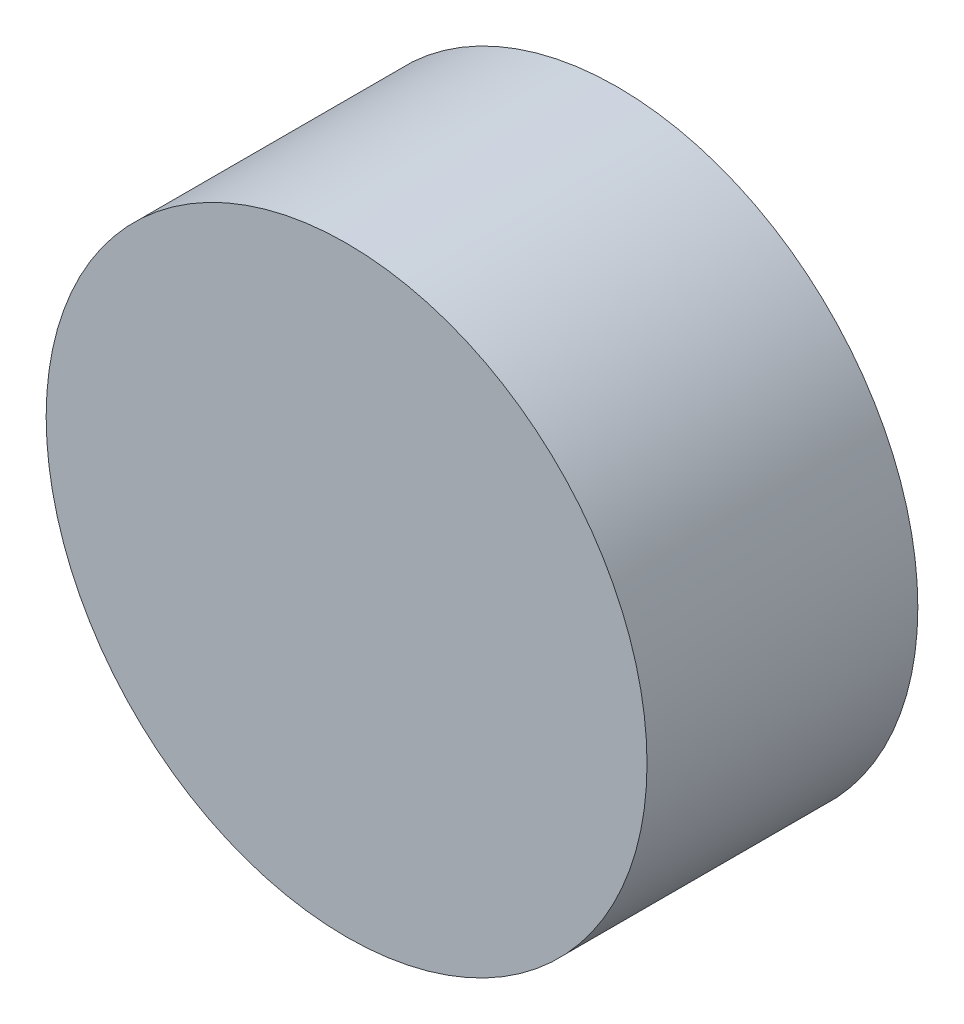
from build123d import *

# Parameters (mm, degrees)
ESQUISSE1_R        = 35.5
BOSS_EXTRU_1_DEPTH = 32


with BuildPart() as part:
    # Esquisse1 → Boss.-Extru.1 (new body)
    with BuildSketch(Plane.XY):
        Circle(ESQUISSE1_R)
    extrude(amount=BOSS_EXTRU_1_DEPTH)


solid = part.part
